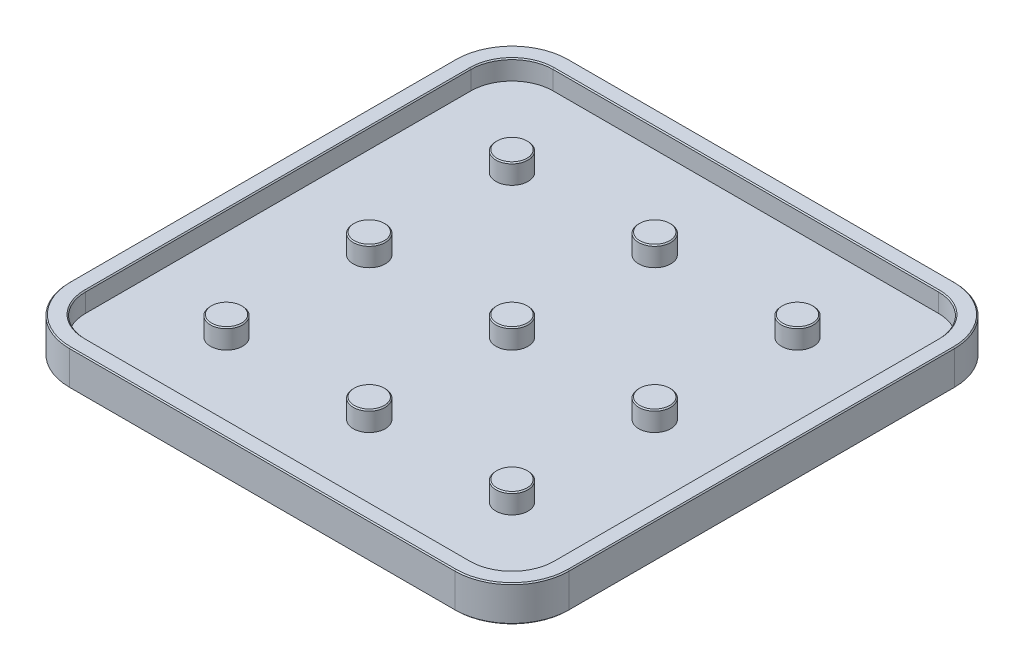
from build123d import *

# Parameters (mm, degrees)
SKETCH1_W           = 70
SKETCH1_H           = 70
BOSS_EXTRUDE1_DEPTH = 2.5
FILLET1_R           = 8
CUT_EXTRUDE1_DEPTH  = 2.75
SKETCH3_R           = 2.25
BOSS_EXTRUDE2_DEPTH = 2.75
CHAMFER1_SIZE       = 0.15


with BuildPart() as part:
    # Sketch1 → Boss-Extrude1 (new body, symmetric)
    with BuildSketch(Plane(origin=(0, 0, 0), x_dir=(1, 0, 0), z_dir=(0, 1, 0))):
        Rectangle(SKETCH1_W, SKETCH1_H)
    extrude(amount=BOSS_EXTRUDE1_DEPTH, both=True)

    # Fillet1
    fillet1_edges = [part.edges().sort_by_distance(p)[0] for p in [
        (35, 0, 35),
        (-35, 0, 35),
        (-35, 0, -35),
        (35, 0, -35),
    ]]
    fillet(fillet1_edges, radius=FILLET1_R)

    # Sketch2 → Cut-Extrude1 (cut)
    with BuildSketch(Plane(origin=(0, 2.5, 0), x_dir=(1, 0, 0), z_dir=(0, 1, 0))):
        with BuildLine():
            Line((32.75, -27), (32.75, 27))
            ThreePointArc((32.75, 27), (31.065863992, 31.065863992), (27, 32.75))
            Line((27, 32.75), (-27, 32.75))
            ThreePointArc((-27, 32.75), (-31.065863992, 31.065863992), (-32.75, 27))
            Line((-32.75, 27), (-32.75, -27))
            ThreePointArc((-32.75, -27), (-31.065863992, -31.065863992), (-27, -32.75))
            Line((-27, -32.75), (27, -32.75))
            ThreePointArc((27, -32.75), (31.065863992, -31.065863992), (32.75, -27))
        make_face()
    extrude(amount=-CUT_EXTRUDE1_DEPTH, mode=Mode.SUBTRACT)

    # Sketch3 → Boss-Extrude2 (add)
    with BuildSketch(Plane(origin=(0, -0.25, 0), x_dir=(1, 0, 0), z_dir=(0, 1, 0))):
        with Locations((-20, 20)):
            Circle(SKETCH3_R)
        with Locations((0, 20)):
            Circle(SKETCH3_R)
        with Locations((20, 20)):
            Circle(SKETCH3_R)
        Circle(SKETCH3_R)
        with Locations((20, 0)):
            Circle(SKETCH3_R)
        with Locations((0, -20)):
            Circle(SKETCH3_R)
        with Locations((20, -20)):
            Circle(SKETCH3_R)
        with Locations((-20, 0)):
            Circle(SKETCH3_R)
        with Locations((-20, -20)):
            Circle(SKETCH3_R)
    extrude(amount=BOSS_EXTRUDE2_DEPTH)

    # Chamfer1
    chamfer1_edges = [part.edges().sort_by_distance(p)[0] for p in [
        (35, 2.5, 0),
        (35, -2.5, 0),
        (0, 2.5, -35),
        (-35, 2.5, 0),
        (0, 2.5, 35),
        (-32.656854249, 2.5, 32.656854249),
        (-32.656854249, 2.5, -32.656854249),
        (32.656854249, 2.5, 32.656854249),
        (32.656854249, 2.5, -32.656854249),
        (0, -2.5, -35),
        (0, -2.5, 35),
        (-35, -2.5, 0),
        (-32.656854249, -2.5, 32.656854249),
        (-32.656854249, -2.5, -32.656854249),
        (32.656854249, -2.5, 32.656854249),
        (32.656854249, -2.5, -32.656854249),
        (31.065863992, 2.5, -31.065863992),
        (0, 2.5, -32.75),
        (-31.065863992, 2.5, -31.065863992),
        (-32.75, 2.5, 0),
        (-31.065863992, 2.5, 31.065863992),
        (0, 2.5, 32.75),
        (31.065863992, 2.5, 31.065863992),
        (32.75, 2.5, 0),
        (-22.25, 2.5, -20),
        (-2.25, 2.5, -20),
        (17.75, 2.5, -20),
        (-2.25, 2.5, 0),
        (17.75, 2.5, 0),
        (-2.25, 2.5, 20),
        (17.75, 2.5, 20),
        (-22.25, 2.5, 0),
        (-22.25, 2.5, 20),
    ]]
    chamfer(chamfer1_edges, length=CHAMFER1_SIZE)


solid = part.part
